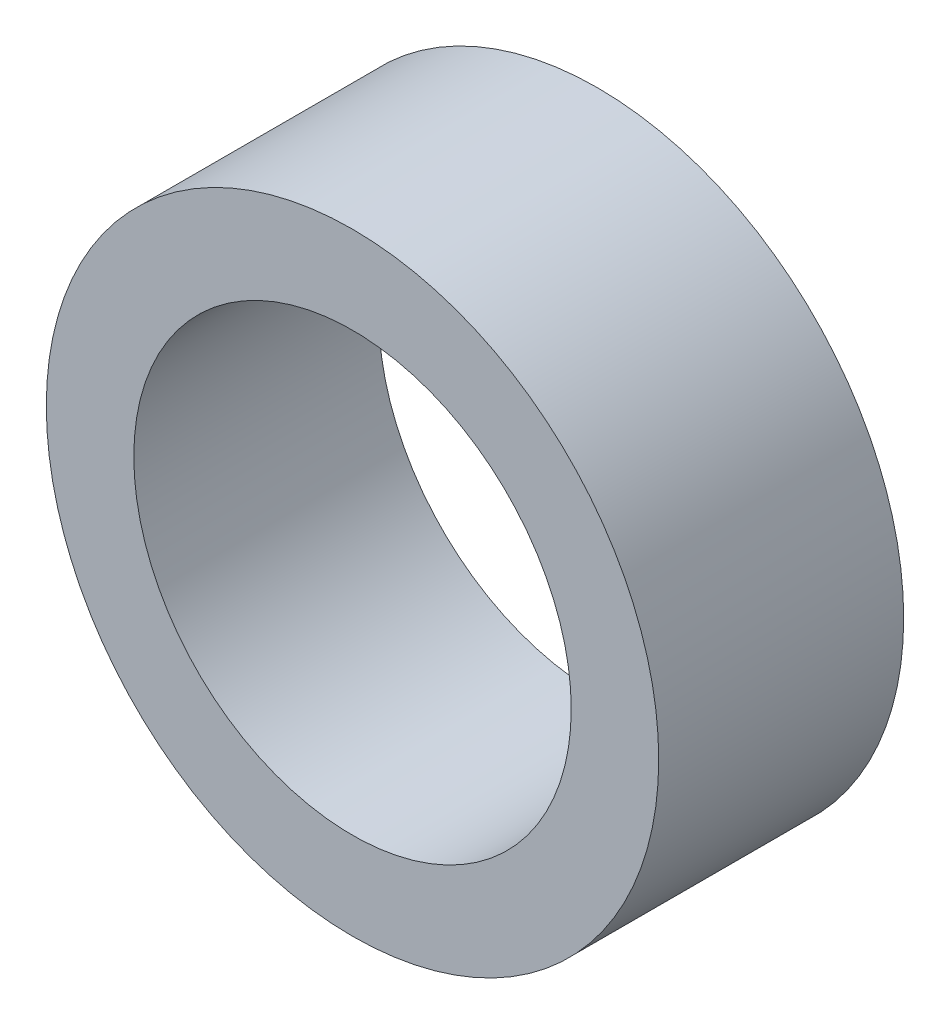
from build123d import *

# Parameters (mm, degrees)
SKETCH_1_R      = 3.5
SKETCH_1_R_2    = 2.5
EXTRUDE_1_DEPTH = 2.8


with BuildPart() as part:
    # 草图1 → 凸台-拉伸1 (new body)
    with BuildSketch(Plane.XY):
        Circle(SKETCH_1_R)
        Circle(SKETCH_1_R_2, mode=Mode.SUBTRACT)
    extrude(amount=EXTRUDE_1_DEPTH)


solid = part.part
